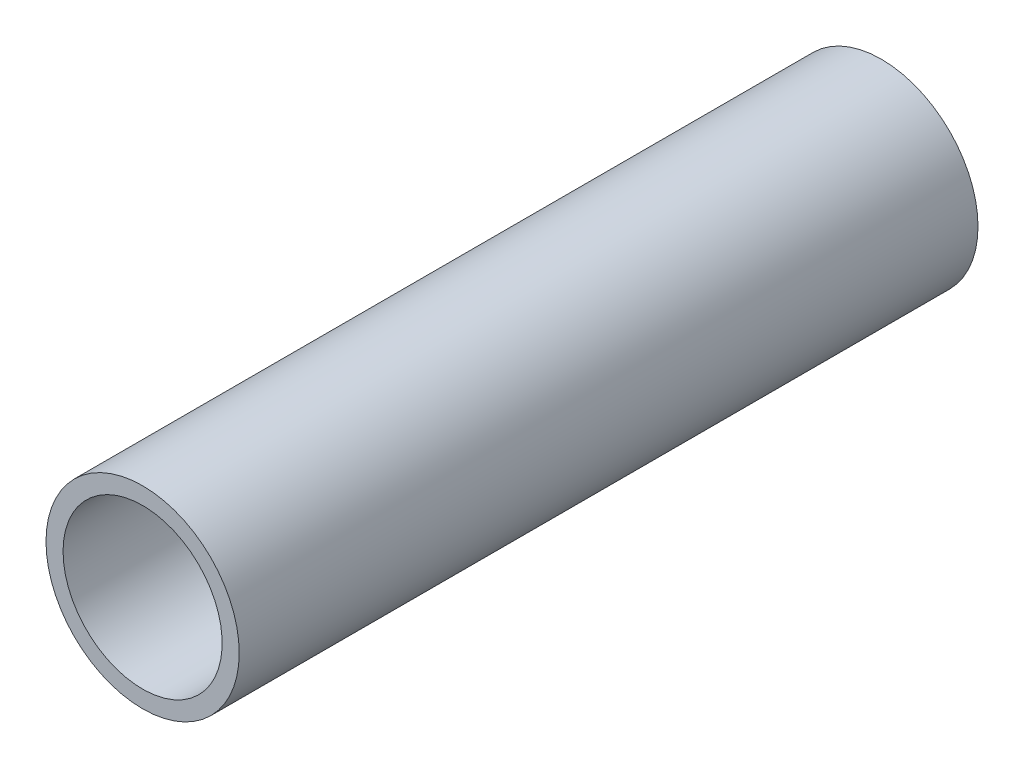
from build123d import *

# Parameters (mm, degrees)
SKETCH1_R                = 17
SKETCH1_R_2              = 14
BOSS_EXTRUDE1_DEPTH      = 40
BOSS_EXTRUDE1_DEPTH_BACK = 90


with BuildPart() as part:
    # Sketch1 → Boss-Extrude1 (new body, two sides)
    with BuildSketch(Plane.XY) as boss_extrude1_sk:
        with Locations((347.5, -26)):
            Circle(SKETCH1_R)
        with Locations((347.5, -26)):
            Circle(SKETCH1_R_2, mode=Mode.SUBTRACT)
    extrude(amount=BOSS_EXTRUDE1_DEPTH)
    extrude(boss_extrude1_sk.sketch, amount=-BOSS_EXTRUDE1_DEPTH_BACK)


solid = part.part
